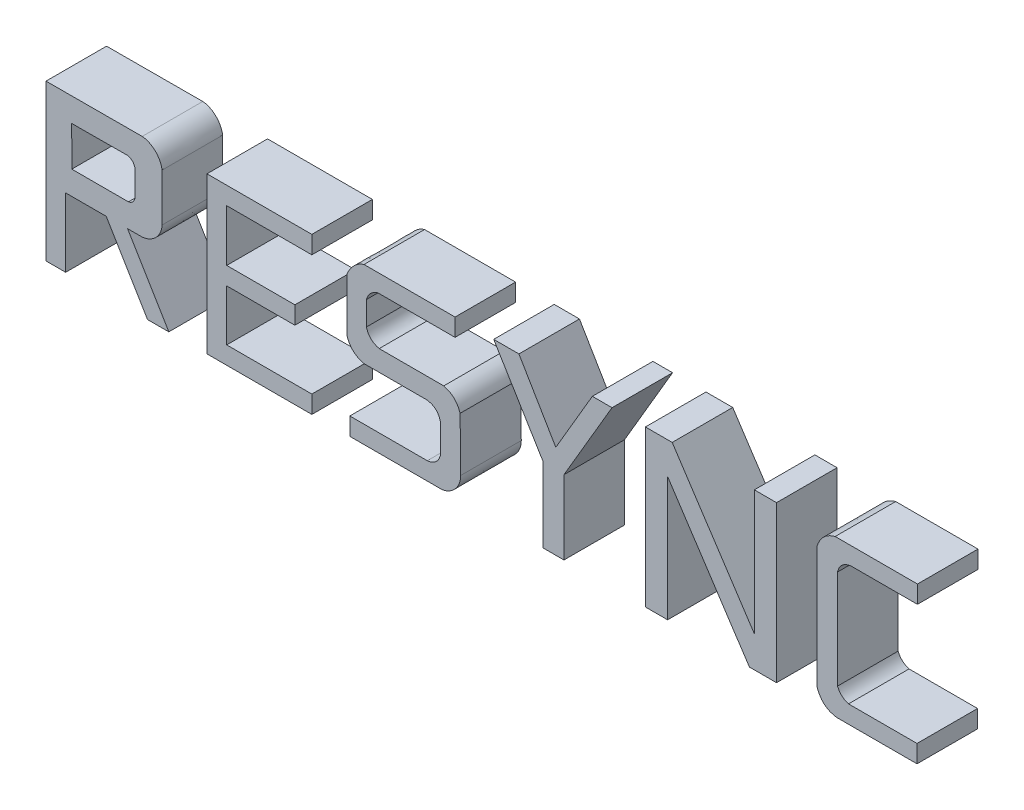
from build123d import *

# Parameters (mm, degrees)
BOSS_EXTRUDE1_DEPTH   = 2
BOSS_EXTRUDE1_2_DEPTH = 2
BOSS_EXTRUDE1_3_DEPTH = 2
BOSS_EXTRUDE1_4_DEPTH = 2
BOSS_EXTRUDE1_5_DEPTH = 2
BOSS_EXTRUDE1_6_DEPTH = 2


with BuildPart() as part:
    # Sketch39 → Boss-Extrude1 (new body)
    with BuildSketch(Plane.XY):
        with BuildLine():
            Line((-10.988283658, 4.551040787), (-10.988283658, 6.121393355))
            add(Edge.make_bspline(
                [(-10.988283658, 6.121393355), (-11.00704669, 6.282203169), (-11.173296334, 6.592730983), (-11.484431359, 6.74747302), (-11.644117832, 6.757612852)],
                knots=[0.009746009, 0.009746009, 0.009746009, 0.009746009, 0.502150435, 0.99455486, 0.99455486, 0.99455486, 0.99455486], degree=3))
            Line((-11.644117832, 6.757612852), (-14.822474371, 6.750608985))
            Line((-14.822474371, 6.750608985), (-14.822474371, 1.605742473))
            Line((-14.822474371, 1.605742473), (-14.172776349, 1.605742473))
            Line((-14.172776349, 1.605742473), (-14.172776349, 3.877872176))
            Line((-14.172776349, 3.877872176), (-12.834670971, 3.877872176))
            Line((-12.834670971, 3.877872176), (-11.469947647, 1.605742473))
            Line((-11.469947647, 1.605742473), (-10.765486226, 1.605742473))
            Line((-10.765486226, 1.605742473), (-12.130209551, 3.877872176))
            Line((-12.130209551, 3.877872176), (-11.645941212, 3.877872176))
            add(Edge.make_bspline(
                [(-11.645941212, 3.877872176), (-11.479810552, 3.891181232), (-11.150934038, 4.046289879), (-10.994428406, 4.383410561), (-10.988283658, 4.551040787)],
                knots=[0.006459962, 0.006459962, 0.006459962, 0.006459962, 0.501839121, 0.99721828, 0.99721828, 0.99721828, 0.99721828], degree=3))
        make_face()
        with BuildLine():
            add(Edge.make_bspline(
                [(-11.884951007, 5.735076037), (-11.928592054, 5.922883289), (-12.120490935, 5.97197097)],
                knots=[0, 0, 0, 1, 1, 1], degree=2))
            Line((-12.120490935, 5.97197097), (-13.972776349, 5.964685241))
            Line((-13.972776349, 5.964685241), (-13.969898423, 4.658681327))
            Line((-13.969898423, 4.658681327), (-12.098915788, 4.658681327))
            add(Edge.make_bspline(
                [(-12.098915788, 4.658681327), (-11.921884887, 4.693884027), (-11.884951007, 4.869171619)],
                knots=[0, 0, 0, 1, 1, 1], degree=2))
            Line((-11.884951007, 4.869171619), (-11.884951007, 5.735076037))
        make_face(mode=Mode.SUBTRACT)
    extrude(amount=BOSS_EXTRUDE1_DEPTH)


with BuildPart() as body_2:
    # Sketch39 → Boss-Extrude1 2 (new body)
    with BuildSketch(Plane.XY):
        Polygon((-8.852624131, 6.17197097), (-6.04007284, 6.17197097), (-6.04007284, 6.757625765), (-9.50478091, 6.757625765), (-9.50478091, 1.605742473), (-6.04007284, 1.605742473), (-6.04007284, 2.189085691), (-8.852624131, 2.189085691), (-8.852624131, 3.877872176), (-6.600945529, 3.877872176), (-6.600945529, 4.462436919), (-8.852624131, 4.462436919), align=None)
    extrude(amount=BOSS_EXTRUDE1_2_DEPTH)


with BuildPart() as body_3:
    # Sketch39 → Boss-Extrude1 3 (new body)
    with BuildSketch(Plane.XY):
        with BuildLine():
            Line((-4.31918684, 3.921709693), (-2.264105173, 3.921709693))
            add(Edge.make_bspline(
                [(-2.264105173, 3.921709693), (-2.154639921, 3.914325878), (-1.986409154, 3.863461196), (-1.839458379, 3.672963809), (-1.81040129, 3.577276033), (-1.797178545, 3.52732652)],
                knots=[-0.015331724, -0.015331724, -0.015331724, -0.015331724, 0.522921565, 0.79204821, 1.061174854, 1.061174854, 1.061174854, 1.061174854], degree=3))
            Line((-1.797178545, 3.52732652), (-1.797178545, 2.543271203))
            add(Edge.make_bspline(
                [(-1.797178545, 2.543271203), (-1.803440917, 2.524560078), (-1.813323353, 2.491570533), (-1.858881539, 2.391714634), (-1.974882575, 2.250067944), (-2.127263158, 2.198005446), (-2.226776537, 2.189085691)],
                knots=[-0.09060457, -0.09060457, -0.09060457, -0.09060457, 0.048789434, 0.188183438, 0.466971445, 1.02454746, 1.02454746, 1.02454746, 1.02454746], degree=3))
            Line((-2.226776537, 2.189085691), (-4.78659772, 2.189085691))
            Line((-4.78659772, 2.189085691), (-4.78659772, 1.605742473))
            Line((-4.78659772, 1.605742473), (-1.752241274, 1.605742473))
            add(Edge.make_bspline(
                [(-1.752241274, 1.605742473), (-1.584005346, 1.621436496), (-1.258554608, 1.804548205), (-1.120255268, 2.14933294), (-1.122232733, 2.318581265)],
                knots=[0.007181502, 0.007181502, 0.007181502, 0.007181502, 0.503590751, 1, 1, 1, 1], degree=3))
            Line((-1.122232733, 2.318581265), (-1.142876363, 4.085439074))
            add(Edge.make_bspline(
                [(-1.142876363, 4.085439074), (-1.163275986, 4.150364388), (-1.220959146, 4.282078899), (-1.333629162, 4.420488379), (-1.477851905, 4.528562375), (-1.615325329, 4.583040112), (-1.682504061, 4.601815782)],
                knots=[0.027377997, 0.027377997, 0.027377997, 0.027377997, 0.264291667, 0.501205336, 0.738119006, 0.975032676, 0.975032676, 0.975032676, 0.975032676], degree=3))
            Line((-1.682504061, 4.601815782), (-3.816139694, 4.601815782))
            add(Edge.make_bspline(
                [(-3.816139694, 4.601815782), (-3.915190479, 4.627351322), (-4.059790564, 4.688936865), (-4.193915815, 4.872629493), (-4.222887106, 4.962861869), (-4.236596871, 5.010030129)],
                knots=[-0.064176492, -0.064176492, -0.064176492, -0.064176492, 0.504399477, 0.788687462, 1.072975446, 1.072975446, 1.072975446, 1.072975446], degree=3))
            Line((-4.236596871, 5.010030129), (-4.236596871, 5.795262738))
            add(Edge.make_bspline(
                [(-4.236596871, 5.795262738), (-4.230560454, 5.813588277), (-4.220915246, 5.846095474), (-4.178017391, 5.942859759), (-4.106912088, 6.039513012), (-3.98112845, 6.133372682), (-3.903388535, 6.161305772), (-3.86235149, 6.176026335)],
                knots=[-0.097478004, -0.097478004, -0.097478004, -0.097478004, 0.05269756, 0.202873124, 0.503224252, 0.80357538, 1.103926508, 1.103926508, 1.103926508, 1.103926508], degree=3))
            Line((-3.86235149, 6.176026335), (-1.309628903, 6.176026335))
            Line((-1.309628903, 6.176026335), (-1.309628903, 6.757625765))
            Line((-1.309628903, 6.757625765), (-4.317354317, 6.757625765))
            add(Edge.make_bspline(
                [(-4.317354317, 6.757625765), (-4.575034459, 6.685206862), (-4.791209886, 6.438981098), (-4.88278942, 6.187472167)],
                knots=[0.025806348, 0.025806348, 0.025806348, 0.025806348, 0.96595456, 0.96595456, 0.96595456, 0.96595456], degree=3))
            Line((-4.88278942, 6.187472167), (-4.88278942, 4.445532593))
            add(Edge.make_bspline(
                [(-4.88278942, 4.445532593), (-4.860219523, 4.37815069), (-4.797521628, 4.241422696), (-4.678503324, 4.09987275), (-4.528695723, 3.991608942), (-4.387952615, 3.939222719), (-4.31918684, 3.921709693)],
                knots=[0.029157333, 0.029157333, 0.029157333, 0.029157333, 0.266244853, 0.503332373, 0.740419893, 0.977507413, 0.977507413, 0.977507413, 0.977507413], degree=3))
        make_face()
    extrude(amount=BOSS_EXTRUDE1_3_DEPTH)


with BuildPart() as body_4:
    # Sketch39 → Boss-Extrude1 4 (new body)
    with BuildSketch(Plane.XY):
        Polygon((3.22629322, 6.757625765), (2.018019143, 4.69458772), (0.80028505, 6.757625765), (-0.033192814, 6.757625765), (1.598107647, 4.078588121), (1.598107647, 1.605742473), (2.288128238, 1.605742473), (2.288128238, 4.046157857), (3.876172816, 6.757625765), align=None)
    extrude(amount=BOSS_EXTRUDE1_4_DEPTH)


with BuildPart() as body_5:
    # Sketch39 → Boss-Extrude1 5 (new body)
    with BuildSketch(Plane.XY):
        Polygon((8.576971429, 6.757625765), (8.576971429, 2.640043558), (5.863316031, 6.757625765), (4.978705551, 6.757625765), (4.978705551, 1.605742473), (5.712405759, 1.605742473), (5.712405759, 5.705426313), (8.414265401, 1.605742473), (9.310671637, 1.605742473), (9.310671637, 6.757625765), align=None)
    extrude(amount=BOSS_EXTRUDE1_5_DEPTH)


with BuildPart() as body_6:
    # Sketch39 → Boss-Extrude1 6 (new body)
    with BuildSketch(Plane.XY):
        with BuildLine():
            Line((11.325043158, 5.780885545), (11.325043158, 2.515652083))
            add(Edge.make_bspline(
                [(11.325043158, 2.515652083), (11.341902197, 2.481968516), (11.370249824, 2.419648775), (11.464290389, 2.30593324), (11.553481619, 2.243240751), (11.644148834, 2.203257654), (11.671651986, 2.194685136), (11.687672586, 2.189085691)],
                knots=[-0.165845119, -0.165845119, -0.165845119, -0.165845119, 0.155776513, 0.477398144, 0.799019775, 0.959830591, 1.120641407, 1.120641407, 1.120641407, 1.120641407], degree=3))
            Line((11.687672586, 2.189085691), (13.951295186, 2.189085691))
            Line((13.951295186, 2.189085691), (13.951295186, 1.605742473))
            Line((13.951295186, 1.605742473), (11.290477562, 1.605742473))
            add(Edge.make_bspline(
                [(11.290477562, 1.605742473), (11.212326423, 1.617910271), (11.049577222, 1.663233251), (10.880794592, 1.773268817), (10.74528073, 1.92705959), (10.672479717, 2.087896295), (10.647050594, 2.16615365)],
                knots=[0.012558179, 0.012558179, 0.012558179, 0.012558179, 0.253224998, 0.493891817, 0.734558637, 0.975225456, 0.975225456, 0.975225456, 0.975225456], degree=3))
            Line((10.647050594, 2.16615365), (10.647050594, 6.175465099))
            add(Edge.make_bspline(
                [(10.647050594, 6.175465099), (10.66957151, 6.248897308), (10.733553746, 6.39809872), (10.859359951, 6.555033149), (11.020204051, 6.676608784), (11.172151253, 6.736918996), (11.246607096, 6.757625765)],
                knots=[0.025178878, 0.025178878, 0.025178878, 0.025178878, 0.263179104, 0.501179329, 0.739179555, 0.97717978, 0.97717978, 0.97717978, 0.97717978], degree=3))
            Line((11.246607096, 6.757625765), (13.965921312, 6.757625765))
            Line((13.965921312, 6.757625765), (13.965921312, 6.176026335))
            Line((13.965921312, 6.176026335), (11.796611462, 6.176026335))
            add(Edge.make_bspline(
                [(11.796611462, 6.176026335), (11.686388353, 6.169172127), (11.51677012, 6.117704632), (11.368900387, 5.92709547), (11.338859704, 5.831005762), (11.325043158, 5.780885545)],
                knots=[-0.014072679, -0.014072679, -0.014072679, -0.014072679, 0.524244875, 0.793403652, 1.062562429, 1.062562429, 1.062562429, 1.062562429], degree=3))
        make_face()
    extrude(amount=BOSS_EXTRUDE1_6_DEPTH)


solid = Compound([part.part, body_2.part, body_3.part, body_4.part, body_5.part, body_6.part])
